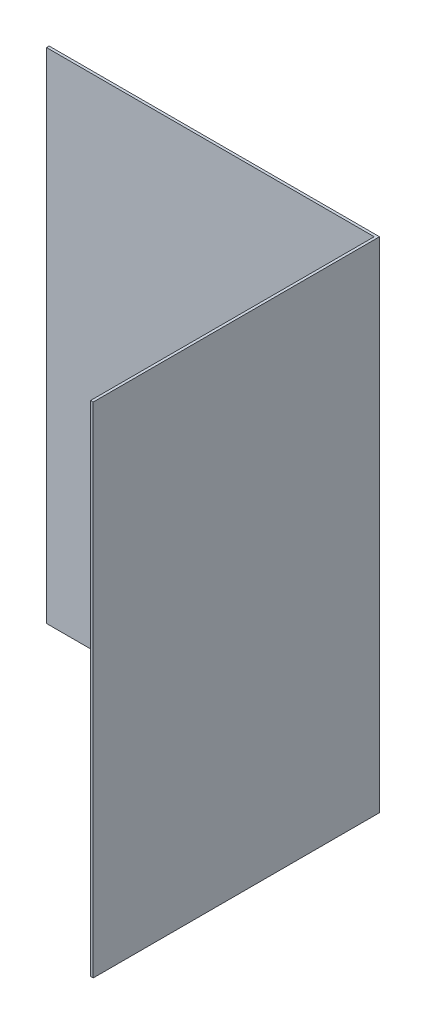
from build123d import *

# Parameters (mm, degrees)
SKETCH1_W           = 19.05
SKETCH1_H           = 28.763083029
SKETCH1_R           = 1.5875
BOSS_EXTRUDE1_DEPTH = 0.1524
SKETCH2_W           = 0.1524
SKETCH2_H           = 28.763083029
BOSS_EXTRUDE2_DEPTH = 16.357339


with BuildPart() as part:
    # Sketch1 → Boss-Extrude1 (new body)
    with BuildSketch(Plane.XY):
        with Locations((6.35, -0.087691515)):
            Rectangle(SKETCH1_W, SKETCH1_H)
        with Locations((9.525, 0)):
            Circle(SKETCH1_R, mode=Mode.SUBTRACT)
    extrude(amount=BOSS_EXTRUDE1_DEPTH)

    # Sketch2 → Boss-Extrude2 (add)
    with BuildSketch(Plane.XY.offset(0.1524)):
        with Locations((15.7988, -0.087691515)):
            Rectangle(SKETCH2_W, SKETCH2_H)
    extrude(amount=BOSS_EXTRUDE2_DEPTH)


solid = part.part
